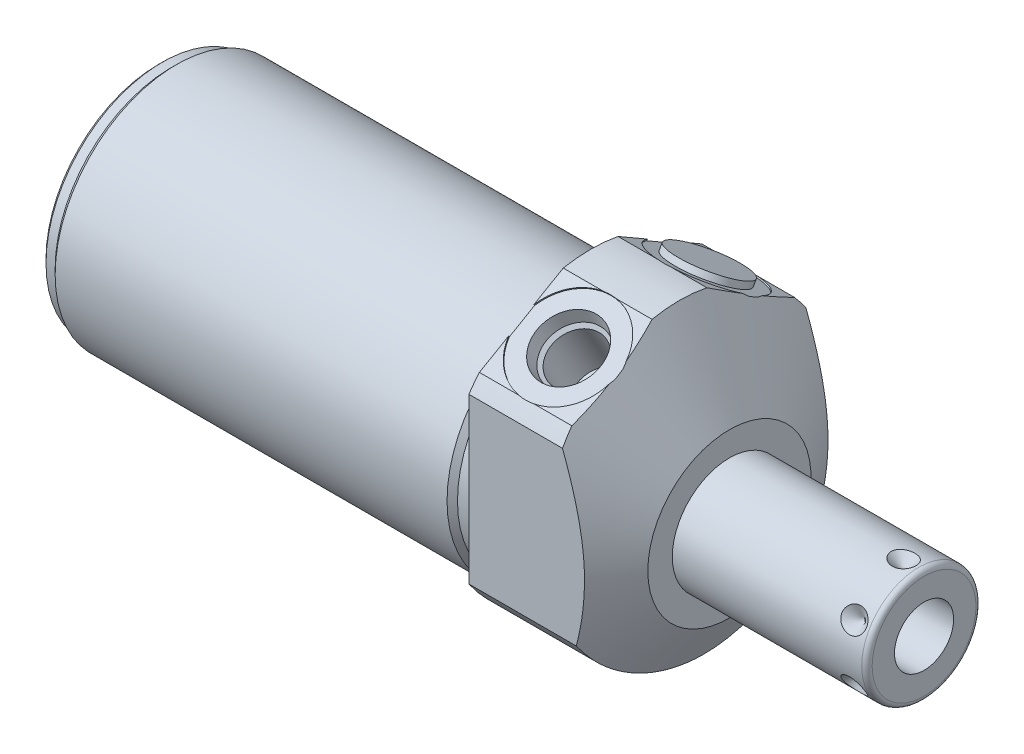
from build123d import *

# Parameters (mm, degrees)
SKETCH1_R           = 28.575
EXTRUDE1_DEPTH      = 27.0002
EXTRUDE1_DEPTH_BACK = 84.1248
CUT_EXTRUDE1_REACH  = 86.125
SKETCH2_R           = 28.575
SKETCH2_R_2         = 23.622
CUT_EXTRUDE3_START  = -27.0002
CUT_EXTRUDE3_DEPTH  = 27.0002
SKETCH18_R          = 9.525
CUT_EXTRUDE4_DEPTH  = 0.254
SKETCH19_R          = 9.525
CUT_EXTRUDE5_DEPTH  = 0.254
CHAMFER1_SIZE       = 0.762
SKETCH15_R          = 6.9469
EXTRUDE2_DEPTH      = 1.27
CIRPATTERN1_COUNT   = 6


with BuildPart() as part:
    # Sketch1 → Extrude1 (new body, two sides)
    with BuildSketch(Plane(origin=(0, 0, 0), x_dir=(0, 0, -1), z_dir=(1, 0, 0))) as extrude1_sk:
        Circle(SKETCH1_R)
    extrude(amount=EXTRUDE1_DEPTH)
    extrude(extrude1_sk.sketch, amount=-EXTRUDE1_DEPTH_BACK)

    # Sketch2 → Cut-Extrude1 (cut, up to next)
    with BuildSketch(Plane(origin=(0, 0, 0), x_dir=(0, 0, -1), z_dir=(1, 0, 0)), mode=Mode.PRIVATE) as cut_extrude1_sk1:
        Circle(SKETCH2_R)
        with Locations((0, -4.191)):
            Circle(SKETCH2_R_2, mode=Mode.SUBTRACT)
    cut_extrude1_tool1 = extrude(cut_extrude1_sk1.sketch, amount=-CUT_EXTRUDE1_REACH, mode=Mode.PRIVATE) & part.part
    add(cut_extrude1_tool1.solids().sort_by_distance((0, 0, 27.766777))[0], mode=Mode.SUBTRACT)

    # Sketch4 → Cut-Extrude3 (cut)
    with BuildSketch(Plane.ZY.offset(CUT_EXTRUDE3_START)):
        with BuildLine():
            Line((23.6855, -25.666178421), (23.6855, 17.476089577))
            Line((23.6855, 17.476089577), (0, 31.150919378))
            Line((0, 31.150919378), (-23.6855, 17.476089577))
            Line((-23.6855, 17.476089577), (-23.6855, -25.666178421))
            ThreePointArc((-23.6855, -25.666178421), (0, 34.925), (23.6855, -25.666178421))
        make_face()
    extrude(amount=CUT_EXTRUDE3_DEPTH, mode=Mode.SUBTRACT)

    # Sketch6 → Cut-Revolve2 (revolve, cut)
    with BuildSketch(Plane.XY, mode=Mode.PRIVATE) as cut_revolve2_sk:
        Polygon((0.750392661, 57.15), (27.0002, 11.684), (27.0002, 57.15), align=None)
    revolve(cut_revolve2_sk.sketch.rotate(Axis((-0.562097706, -4.191, 0), (1, 0, 0)), 270), axis=Axis((-0.562097706, -4.191, 0), (1, 0, 0)), mode=Mode.SUBTRACT)  # turned: the seam where the file's is

    # S2D0002 → Cut-Revolve3 (revolve, cut)
    with BuildSketch(Plane(origin=(9.0932, 23.136869081, 13.372742289), x_dir=(0, 0.5, -0.866025404), z_dir=(1, 0, 0))):
        Polygon((0, 0), (6.1849, 0), (5.642306865, -2.5527), (4.9784, -3.216606865), (4.9784, -13.462), (0, -13.462), align=None)
    revolve(axis=Axis((9.0932, 10.895513396, 6.305192289), (0, 0.866025404, 0.5)), mode=Mode.SUBTRACT)

    # Sketch8 → Cut-Revolve4 (revolve, cut)
    with BuildSketch(Plane(origin=(9.0932, 23.136869081, -13.372742289), x_dir=(0, -0.5, -0.866025404), z_dir=(1, 0, 0))):
        Polygon((0, 0), (6.1849, 0), (5.642306865, -2.5527), (4.9784, -3.216606865), (4.9784, -13.462), (0, -13.462), align=None)
    revolve(axis=Axis((9.0932, 10.895513396, -6.305192289), (0, 0.866025404, -0.5)), mode=Mode.SUBTRACT)

    # Sketch18 → Cut-Extrude4 (cut)
    with BuildSketch(Plane(origin=(0, 23.363189534, 13.488743766), x_dir=(1, 0, 0), z_dir=(0, 0.866025404, 0.5))):
        with Locations((9.0932, -0.0127)):
            Circle(SKETCH18_R)
    extrude(amount=-CUT_EXTRUDE4_DEPTH, mode=Mode.SUBTRACT)

    # Sketch19 → Cut-Extrude5 (cut)
    with BuildSketch(Plane(origin=(0, 23.363189534, -13.488743766), x_dir=(1, 0, 0), z_dir=(0, 0.866025404, -0.5))):
        with Locations((9.0932, 0.0127)):
            Circle(SKETCH19_R)
    extrude(amount=-CUT_EXTRUDE5_DEPTH, mode=Mode.SUBTRACT)

    # Sketch10 → Cut-Revolve6 (revolve, cut)
    with BuildSketch(Plane.XY, mode=Mode.PRIVATE) as cut_revolve6_sk:
        Polygon((0, 19.431), (0, 18.415), (-3.302, 18.415), (-4.318, 19.431), align=None)
    revolve(cut_revolve6_sk.sketch.rotate(Axis((-4.5339, -4.191, 0), (1, 0, 0)), 90), axis=Axis((-4.5339, -4.191, 0), (1, 0, 0)), mode=Mode.SUBTRACT)  # turned: the seam where the file's is

    # Sketch12 → Cut-Revolve8 (revolve, cut)
    with BuildSketch(Plane.XY, mode=Mode.PRIVATE) as cut_revolve8_sk:
        Polygon((-84.1248, 19.431), (-84.1248, 18.415), (-81.5848, 18.415), (-80.5688, 19.431), align=None)
    revolve(cut_revolve8_sk.sketch.rotate(Axis((-84.3026, -4.191, 0), (1, 0, 0)), 90), axis=Axis((-84.3026, -4.191, 0), (1, 0, 0)), mode=Mode.SUBTRACT)  # turned: the seam where the file's is

    # Chamfer1
    chamfer1_edges = [part.edges().sort_by_distance(p)[0] for p in [
        (-84.1248, -4.191, -22.606),
    ]]
    chamfer(chamfer1_edges, length=CHAMFER1_SIZE)

    # Sketch13 → Revolve1 (revolve)
    with BuildSketch(Plane(origin=(0, 0, 0), x_dir=(0, -1, 0), z_dir=(0, 0, 1)), mode=Mode.PRIVATE) as revolve1_sk:
        with BuildLine():
            Line((4.191, 27.0002), (4.191, 64.8716))
            Line((4.191, 64.8716), (14.2875, 64.8716))
            ThreePointArc((14.2875, 64.8716), (15.00592049, 64.57402049), (15.3035, 63.8556))
            Line((15.3035, 63.8556), (15.3035, 27.0002))
            Line((15.3035, 27.0002), (4.191, 27.0002))
        make_face()
    revolve(revolve1_sk.sketch.rotate(Axis((25.10663, -4.191, 0), (1, 0, 0)), 270), axis=Axis((25.10663, -4.191, 0), (1, 0, 0)))  # turned: the seam where the file's is

    # S2D0001 → Cut-Revolve9 (revolve, cut)
    with BuildSketch(Plane(origin=(64.8716, -9.9441, 0), x_dir=(0, -1, 0), z_dir=(0, 0, 1)), mode=Mode.PRIVATE) as cut_revolve9_sk:
        Polygon((0, 0), (0, -17.018), (-5.7531, -20.474811227), (-5.7531, 0), align=None)
    revolve(cut_revolve9_sk.sketch.rotate(Axis((43.373048211, -4.191, 0), (1, 0, 0)), 270), axis=Axis((43.373048211, -4.191, 0), (1, 0, 0)), mode=Mode.SUBTRACT)  # turned: the seam where the file's is

    # Sketch15 → Extrude2 (add)
    with BuildSketch(Plane(origin=(27.0002, 23.143219081, -13.361743766), x_dir=(0, -0.5, -0.866025404), z_dir=(0, -0.866025404, 0.5))):
        with Locations((0.0127, -17.907)):
            Circle(SKETCH15_R)
    extrude(amount=-EXTRUDE2_DEPTH)

    # Sketch16 → Cut-Revolve10 (revolve, cut)
    with BuildSketch(Plane(origin=(60.9092, 6.9215, 0), x_dir=(-1, 0, 0), z_dir=(0, 0, -1)), mode=Mode.PRIVATE) as cut_revolve10_sk:
        Polygon((0, 0), (2.413, 0), (0, -2.413), align=None)
    cut_revolve10 = revolve(cut_revolve10_sk.sketch.rotate(Axis((60.9092, 2.435048935, 0), (0, 1, 0)), 90), axis=Axis((60.9092, 2.435048935, 0), (0, 1, 0)), mode=Mode.SUBTRACT)  # turned: the seam where the file's is

    # CirPattern1: Cut-Revolve10 ×6 about axis
    cirpattern1_axis = Axis((25.10663, -4.191, 0), (-1, 0, 0))
    for i in range(1, CIRPATTERN1_COUNT):
        add(cut_revolve10.rotate(cirpattern1_axis, i * 360 / CIRPATTERN1_COUNT), mode=Mode.SUBTRACT)


solid = part.part
